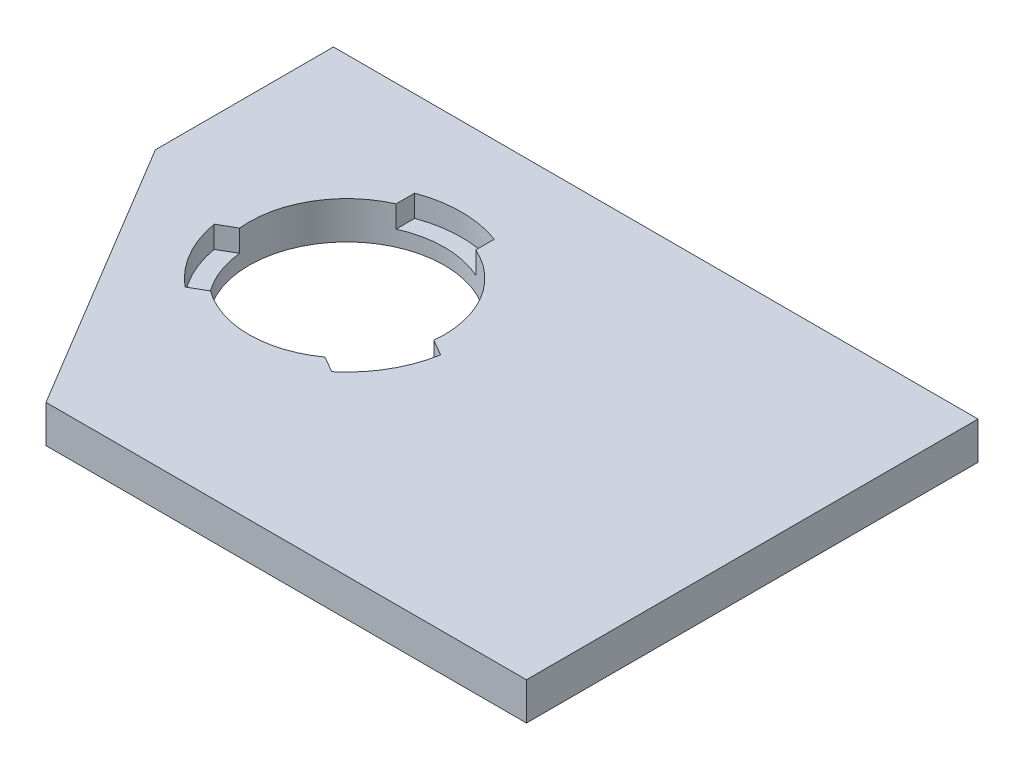
from build123d import *

# Parameters (mm, degrees)
SKETCH1_W           = 82.5
SKETCH1_H           = 57.8
BOSS_EXTRUDE1_DEPTH = 4.8
SKETCH2_R           = 12.5
CUT_EXTRUDE1_DEPTH  = 4.8
CUT_EXTRUDE2_DEPTH  = 2.8
SKETCH4_W           = 82.5
SKETCH4_H           = 57.8
CUT_EXTRUDE3_DEPTH  = 10


with BuildPart() as part:
    # Sketch1 → Boss-Extrude1 (new body)
    with BuildSketch(Plane(origin=(0, 0, 0), x_dir=(1, 0, 0), z_dir=(0, 1, 0))):
        with Locations((20.883891213, 18.735983264)):
            Rectangle(SKETCH1_W, SKETCH1_H)
    boss_extrude1 = extrude(amount=BOSS_EXTRUDE1_DEPTH)

    # Sketch2 → Cut-Extrude1 (cut)
    with BuildSketch(Plane(origin=(0, 4.8, 0), x_dir=(1, 0, 0), z_dir=(0, 1, 0))):
        with Locations((35.633891213, 22.835983264)):
            Circle(SKETCH2_R)
        Polygon((41.133891213, -10.164016736), (62.133891213, 24.835983264), (62.133891213, -10.164016736), align=None)
    cut_extrude1 = extrude(amount=-CUT_EXTRUDE1_DEPTH, mode=Mode.SUBTRACT)

    # Sketch3 → Cut-Extrude2 (cut)
    with BuildSketch(Plane(origin=(0, 4.8, 0), x_dir=(1, 0, 0), z_dir=(0, 1, 0))):
        with BuildLine():
            ThreePointArc((30.533891213, 34.248257358), (33.026538742, 35.061027766), (35.633891213, 35.335983264))
            Line((35.633891213, 35.335983264), (35.633891213, 37.535983264))
            ThreePointArc((35.633891213, 37.535983264), (33.04334785, 37.30592055), (30.533891213, 36.622933615))
            Line((30.533891213, 36.622933615), (30.533891213, 34.248257358))
        make_face()
        with BuildLine():
            Line((35.633891213, 37.535983264), (35.633891213, 35.335983264))
            ThreePointArc((35.633891213, 35.335983264), (38.241243685, 35.061027766), (40.733891213, 34.248257358))
            Line((40.733891213, 34.248257358), (40.733891213, 36.622933615))
            ThreePointArc((40.733891213, 36.622933615), (38.224434576, 37.30592055), (35.633891213, 37.535983264))
        make_face()
        with BuildLine():
            ThreePointArc((48.067210494, 21.546575776), (47.524766551, 18.981494489), (46.459208761, 16.585983264))
            Line((46.459208761, 16.585983264), (48.364464649, 15.485983264))
            ThreePointArc((48.364464649, 15.485983264), (49.460496176, 17.844490982), (50.123740459, 20.359237647))
            Line((50.123740459, 20.359237647), (48.067210494, 21.546575776))
        make_face()
        with BuildLine():
            Line((48.364464649, 15.485983264), (46.459208761, 16.585983264))
            ThreePointArc((46.459208761, 16.585983264), (44.917414079, 14.465427535), (42.967210494, 12.713116657))
            Line((42.967210494, 12.713116657), (45.023740459, 11.525778528))
            ThreePointArc((45.023740459, 11.525778528), (46.869952814, 13.357538258), (48.364464649, 15.485983264))
        make_face()
        with BuildLine():
            Line((22.903317778, 15.485983264), (24.808573666, 16.585983264))
            ThreePointArc((24.808573666, 16.585983264), (23.743015876, 18.981494489), (23.200571933, 21.546575776))
            Line((23.200571933, 21.546575776), (21.144041968, 20.359237647))
            ThreePointArc((21.144041968, 20.359237647), (21.80728625, 17.844490982), (22.903317778, 15.485983264))
        make_face()
        with BuildLine():
            ThreePointArc((28.300571933, 12.713116657), (26.350368348, 14.465427535), (24.808573666, 16.585983264))
            Line((24.808573666, 16.585983264), (22.903317778, 15.485983264))
            ThreePointArc((22.903317778, 15.485983264), (24.397829613, 13.357538258), (26.244041968, 11.525778528))
            Line((26.244041968, 11.525778528), (28.300571933, 12.713116657))
        make_face()
    cut_extrude2 = extrude(amount=-CUT_EXTRUDE2_DEPTH, mode=Mode.SUBTRACT)

    # Mirror1: Boss-Extrude1, Cut-Extrude1, Cut-Extrude2 across plane
    add(boss_extrude1.mirror(Plane(origin=(62.133891213, 4.8, 10.164016736), x_dir=(0, 0, 1), z_dir=(-1, 0, 0))))
    add(cut_extrude1.mirror(Plane(origin=(62.133891213, 4.8, 10.164016736), x_dir=(0, 0, 1), z_dir=(-1, 0, 0))), mode=Mode.SUBTRACT)
    add(cut_extrude2.mirror(Plane(origin=(62.133891213, 4.8, 10.164016736), x_dir=(0, 0, 1), z_dir=(-1, 0, 0))), mode=Mode.SUBTRACT)

    # Sketch4 → Cut-Extrude3 (cut)
    with BuildSketch(Plane(origin=(0, 4.8, 0), x_dir=(1, 0, 0), z_dir=(0, 1, 0))):
        with Locations((20.883891213, 18.735983264)):
            Rectangle(SKETCH4_W, SKETCH4_H)
    extrude(amount=-CUT_EXTRUDE3_DEPTH, mode=Mode.SUBTRACT)


solid = part.part
